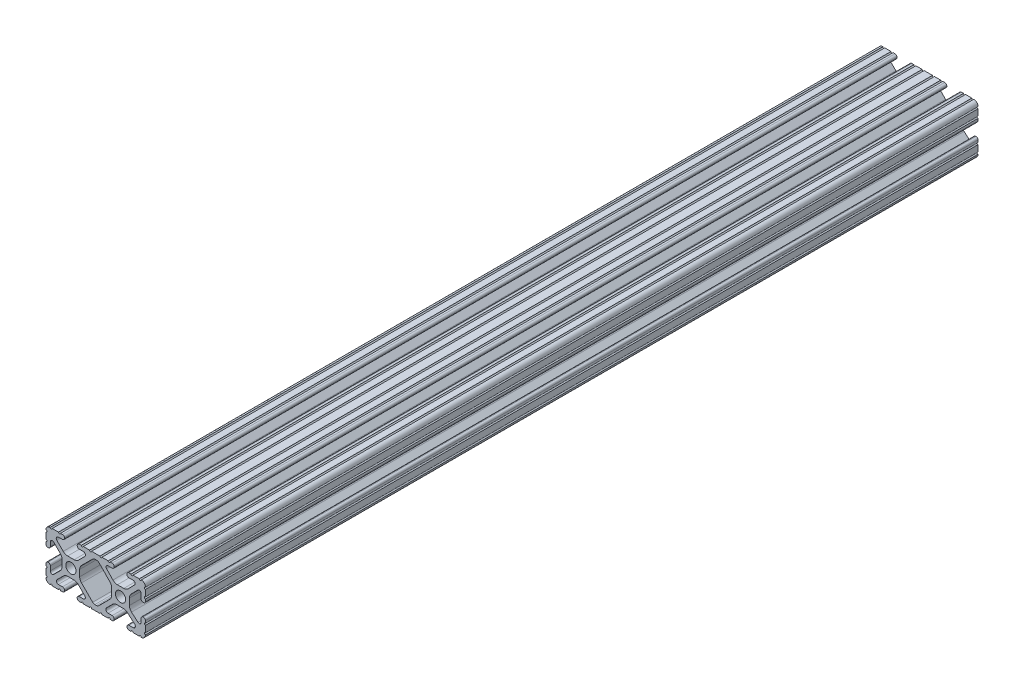
from build123d import *

# Parameters (mm, degrees)
SKETCH1_R           = 2.6035
BOSS_EXTRUDE1_DEPTH = 212.725


with BuildPart() as part:
    # Sketch1 → Boss-Extrude1 (new body, symmetric)
    with BuildSketch(Plane.XY):
        with BuildLine():
            Line((18.01710265, 12.7), (16.98745015, 12.7))
            ThreePointArc((16.98745015, 12.7), (16.245730386, 12.392769614), (15.9385, 11.65104985))
            Line((15.9385, 11.65104985), (15.9385, 11.53922))
            ThreePointArc((15.9385, 11.53922), (16.245750844, 10.797450844), (16.98752, 10.4902))
            Line((16.98752, 10.4902), (19.116384363, 10.4902))
            ThreePointArc((19.116384363, 10.4902), (20.052502933, 9.869096983), (19.844087081, 8.765172272))
            Line((19.844087081, 8.765172272), (16.618993479, 5.455112286))
            ThreePointArc((16.618993479, 5.455112286), (15.578994274, 4.745442459), (14.344932584, 4.4958))
            Line((14.344932584, 4.4958), (11.083317835, 4.4958))
            ThreePointArc((11.083317835, 4.4958), (9.854330953, 4.743306833), (8.816955189, 5.447238587))
            Line((8.816955189, 5.447238587), (5.564154119, 8.762652677))
            ThreePointArc((5.564154119, 8.762652677), (5.352591412, 9.867473037), (6.289393385, 10.4902))
            Line((6.289393385, 10.4902), (8.41248, 10.4902))
            ThreePointArc((8.41248, 10.4902), (9.154249156, 10.797450844), (9.4615, 11.53922))
            Line((9.4615, 11.53922), (9.4615, 11.65104985))
            ThreePointArc((9.4615, 11.65104985), (9.154269614, 12.392769614), (8.41254985, 12.7))
            Line((8.41254985, 12.7), (7.38288465, 12.7))
            ThreePointArc((7.38288465, 12.7), (6.87488465, 12.192), (6.36688465, 12.7))
            Line((6.36688465, 12.7), (3.14958095, 12.7))
            ThreePointArc((3.14958095, 12.7), (2.64158095, 12.192), (2.13358095, 12.7))
            Line((2.13358095, 12.7), (-2.13358095, 12.7))
            ThreePointArc((-2.13358095, 12.7), (-2.64158095, 12.192), (-3.14958095, 12.7))
            Line((-3.14958095, 12.7), (-6.36689735, 12.7))
            ThreePointArc((-6.36689735, 12.7), (-6.87489735, 12.192), (-7.38289735, 12.7))
            Line((-7.38289735, 12.7), (-8.41254985, 12.7))
            ThreePointArc((-8.41254985, 12.7), (-9.154269614, 12.392769614), (-9.4615, 11.65104985))
            Line((-9.4615, 11.65104985), (-9.4615, 11.53922))
            ThreePointArc((-9.4615, 11.53922), (-9.154249156, 10.797450844), (-8.41248, 10.4902))
            Line((-8.41248, 10.4902), (-6.283641037, 10.4902))
            ThreePointArc((-6.283641037, 10.4902), (-5.297291557, 9.829633109), (-5.532576693, 8.666071843))
            Line((-5.532576693, 8.666071843), (-8.809985098, 5.416263103))
            ThreePointArc((-8.809985098, 5.416263103), (-9.836720513, 4.734920264), (-11.045536121, 4.4958))
            Line((-11.045536121, 4.4958), (-14.354463879, 4.4958))
            ThreePointArc((-14.354463879, 4.4958), (-15.563279487, 4.734920264), (-16.590014902, 5.416263103))
            Line((-16.590014902, 5.416263103), (-19.867423307, 8.666071843))
            ThreePointArc((-19.867423307, 8.666071843), (-20.102708443, 9.829633109), (-19.116358963, 10.4902))
            Line((-19.116358963, 10.4902), (-16.98752, 10.4902))
            ThreePointArc((-16.98752, 10.4902), (-16.245750844, 10.797450844), (-15.9385, 11.53922))
            Line((-15.9385, 11.53922), (-15.9385, 11.65104985))
            ThreePointArc((-15.9385, 11.65104985), (-16.245730386, 12.392769614), (-16.98745015, 12.7))
            Line((-16.98745015, 12.7), (-18.01711535, 12.7))
            ThreePointArc((-18.01711535, 12.7), (-18.52511535, 12.192), (-19.03311535, 12.7))
            Line((-19.03311535, 12.7), (-22.2504, 12.7))
            ThreePointArc((-22.2504, 12.7), (-22.758323491, 12.192000006), (-23.266399977, 12.699846982))
            ThreePointArc((-23.266399977, 12.699846982), (-24.782522516, 12.082522516), (-25.399846982, 10.566399977))
            ThreePointArc((-25.399846982, 10.566399977), (-24.892000006, 10.058323491), (-25.4, 9.5504))
            Line((-25.4, 9.5504), (-25.4, 6.3330836))
            ThreePointArc((-25.4, 6.3330836), (-24.892, 5.8250836), (-25.4, 5.3170836))
            Line((-25.4, 5.3170836), (-25.4, 4.237520184))
            ThreePointArc((-25.4, 4.237520184), (-25.107393763, 3.531106237), (-24.400979816, 3.2385))
            Line((-24.400979816, 3.2385), (-24.23922, 3.2385))
            ThreePointArc((-24.23922, 3.2385), (-23.497450844, 3.545750844), (-23.1902, 4.28752))
            Line((-23.1902, 4.28752), (-23.1902, 6.334741132))
            ThreePointArc((-23.1902, 6.334741132), (-22.556026952, 7.286023527), (-21.434002553, 7.066535717))
            Line((-21.434002553, 7.066535717), (-18.147950853, 3.808156468))
            ThreePointArc((-18.147950853, 3.808156468), (-17.452759693, 2.774838327), (-17.208501877, 1.553619571))
            Line((-17.208501877, 1.553619571), (-17.208501877, -1.695179196))
            ThreePointArc((-17.208501877, -1.695179196), (-17.450738657, -2.911536421), (-18.140486065, -3.942289578))
            Line((-18.140486065, -3.942289578), (-21.431579576, -7.227386226))
            ThreePointArc((-21.431579576, -7.227386226), (-22.55444896, -7.449940594), (-23.1902, -6.498002195))
            Line((-23.1902, -6.498002195), (-23.1902, -4.28752))
            ThreePointArc((-23.1902, -4.28752), (-23.497450844, -3.545750844), (-24.23922, -3.2385))
            Line((-24.23922, -3.2385), (-24.35098, -3.2385))
            ThreePointArc((-24.35098, -3.2385), (-25.092749156, -3.545750844), (-25.4, -4.28752))
            Line((-25.4, -4.28752), (-25.4, -5.3171344))
            ThreePointArc((-25.4, -5.3171344), (-24.892, -5.8251344), (-25.4, -6.3331344))
            Line((-25.4, -6.3331344), (-25.4, -9.5504))
            ThreePointArc((-25.4, -9.5504), (-24.892000006, -10.058323491), (-25.399846982, -10.566399977))
            ThreePointArc((-25.399846982, -10.566399977), (-24.782522516, -12.082522516), (-23.266399977, -12.699846982))
            ThreePointArc((-23.266399977, -12.699846982), (-22.758323491, -12.192000006), (-22.2504, -12.7))
            Line((-22.2504, -12.7), (-19.03308995, -12.7))
            ThreePointArc((-19.03308995, -12.7), (-18.52508995, -12.192), (-18.01708995, -12.7))
            Line((-18.01708995, -12.7), (-16.9874692, -12.7))
            ThreePointArc((-16.9874692, -12.7), (-16.245700044, -12.392749156), (-15.9384492, -11.65098))
            Line((-15.9384492, -11.65098), (-15.9384492, -11.53922))
            ThreePointArc((-15.9384492, -11.53922), (-16.245700044, -10.797450844), (-16.9874692, -10.4902))
            Line((-16.9874692, -10.4902), (-19.116358963, -10.4902))
            ThreePointArc((-19.116358963, -10.4902), (-20.055197748, -9.862578342), (-19.834124023, -8.755124678))
            Line((-19.834124023, -8.755124678), (-16.49660751, -5.423689618))
            ThreePointArc((-16.49660751, -5.423689618), (-15.467274017, -4.736928798), (-14.253591699, -4.4958))
            Line((-14.253591699, -4.4958), (-11.146408301, -4.4958))
            ThreePointArc((-11.146408301, -4.4958), (-9.932725983, -4.736928798), (-8.90339249, -5.423689618))
            Line((-8.90339249, -5.423689618), (-5.565875977, -8.755124678))
            ThreePointArc((-5.565875977, -8.755124678), (-5.344802252, -9.862578342), (-6.283641037, -10.4902))
            Line((-6.283641037, -10.4902), (-8.4125308, -10.4902))
            ThreePointArc((-8.4125308, -10.4902), (-9.154299956, -10.797450844), (-9.4615508, -11.53922))
            Line((-9.4615508, -11.53922), (-9.4615508, -11.65098))
            ThreePointArc((-9.4615508, -11.65098), (-9.154299956, -12.392749156), (-8.4125308, -12.7))
            Line((-8.4125308, -12.7), (-7.38287195, -12.7))
            ThreePointArc((-7.38287195, -12.7), (-6.87487195, -12.192), (-6.36687195, -12.7))
            Line((-6.36687195, -12.7), (-3.14960635, -12.7))
            ThreePointArc((-3.14960635, -12.7), (-2.64160635, -12.192), (-2.13360635, -12.7))
            Line((-2.13360635, -12.7), (2.13360635, -12.7))
            ThreePointArc((2.13360635, -12.7), (2.64159365, -12.1920127), (3.14958095, -12.7))
            Line((3.14958095, -12.7), (6.36691005, -12.7))
            ThreePointArc((6.36691005, -12.7), (6.87491005, -12.192), (7.38291005, -12.7))
            Line((7.38291005, -12.7), (8.4125308, -12.7))
            ThreePointArc((8.4125308, -12.7), (9.154299956, -12.392749156), (9.4615508, -11.65098))
            Line((9.4615508, -11.65098), (9.4615508, -11.53922))
            ThreePointArc((9.4615508, -11.53922), (9.154299956, -10.797450844), (8.4125308, -10.4902))
            Line((8.4125308, -10.4902), (6.289393385, -10.4902))
            ThreePointArc((6.289393385, -10.4902), (5.231590322, -9.783049717), (5.480677245, -8.535265862))
            Line((5.480677245, -8.535265862), (8.597933595, -5.423689618))
            ThreePointArc((8.597933595, -5.423689618), (9.627267088, -4.736928798), (10.840949406, -4.4958))
            Line((10.840949406, -4.4958), (14.102564155, -4.4958))
            ThreePointArc((14.102564155, -4.4958), (15.215927525, -4.697410182), (16.187895372, -5.276636531))
            Line((16.187895372, -5.276636531), (19.868247549, -8.482246082))
            ThreePointArc((19.868247549, -8.482246082), (20.188435806, -9.746879864), (19.116384363, -10.4902))
            Line((19.116384363, -10.4902), (16.9874692, -10.4902))
            ThreePointArc((16.9874692, -10.4902), (16.245700044, -10.797450844), (15.9384492, -11.53922))
            Line((15.9384492, -11.53922), (15.9384492, -11.65098))
            ThreePointArc((15.9384492, -11.65098), (16.245700044, -12.392749156), (16.9874692, -12.7))
            Line((16.9874692, -12.7), (18.01710265, -12.7))
            ThreePointArc((18.01710265, -12.7), (18.52510265, -12.192), (19.03310265, -12.7))
            Line((19.03310265, -12.7), (22.2504, -12.7))
            ThreePointArc((22.2504, -12.7), (22.758323491, -12.192000006), (23.266399977, -12.699846982))
            ThreePointArc((23.266399977, -12.699846982), (24.782522516, -12.082522516), (25.399846982, -10.566399977))
            ThreePointArc((25.399846982, -10.566399977), (24.892000006, -10.058323492), (25.4, -9.550400001))
            Line((25.4, -9.550400001), (25.4, -6.333083592))
            ThreePointArc((25.4, -6.333083592), (24.892000001, -5.825083593), (25.4, -5.317083593))
            Line((25.4, -5.317083593), (25.4, -4.237520184))
            ThreePointArc((25.4, -4.237520184), (25.107393763, -3.531106237), (24.400979816, -3.2385))
            Line((24.400979816, -3.2385), (24.189220184, -3.2385))
            ThreePointArc((24.189220184, -3.2385), (23.482806237, -3.531106237), (23.1902, -4.237520184))
            Line((23.1902, -4.237520184), (23.1902, -6.155876159))
            ThreePointArc((23.1902, -6.155876159), (22.62232736, -7.038258539), (21.583974541, -6.886926384))
            Line((21.583974541, -6.886926384), (18.29817066, -4.024970844))
            ThreePointArc((18.29817066, -4.024970844), (17.493730985, -2.946044689), (17.208501877, -1.630807374))
            Line((17.208501877, -1.630807374), (17.208501877, 1.630807374))
            ThreePointArc((17.208501877, 1.630807374), (17.442348332, 2.82673414), (18.109440981, 3.846495088))
            Line((18.109440981, 3.846495088), (21.526346532, 7.353420386))
            ThreePointArc((21.526346532, 7.353420386), (22.585896263, 7.574939077), (23.1902, 6.676867167))
            Line((23.1902, 6.676867167), (23.1902, 4.237520184))
            ThreePointArc((23.1902, 4.237520184), (23.482806237, 3.531106237), (24.189220184, 3.2385))
            Line((24.189220184, 3.2385), (24.400979816, 3.2385))
            ThreePointArc((24.400979816, 3.2385), (25.107393763, 3.531106237), (25.4, 4.237520184))
            Line((25.4, 4.237520184), (25.4, 5.3170836))
            ThreePointArc((25.4, 5.3170836), (24.891949193, 5.825134407), (25.4, 6.333185215))
            Line((25.4, 6.333185215), (25.4, 9.550400015))
            ThreePointArc((25.4, 9.550400015), (24.892000013, 10.058323498), (25.399846982, 10.566399977))
            ThreePointArc((25.399846982, 10.566399977), (24.782522516, 12.082522516), (23.266399977, 12.699846982))
            ThreePointArc((23.266399977, 12.699846982), (22.758323491, 12.192000006), (22.2504, 12.7))
            Line((22.2504, 12.7), (19.03310265, 12.7))
            ThreePointArc((19.03310265, 12.7), (18.52510265, 12.192), (18.01710265, 12.7))
        make_face()
        with Locations((-12.7, 0)):
            Circle(SKETCH1_R, mode=Mode.SUBTRACT)
        with Locations((12.7, 0)):
            Circle(SKETCH1_R, mode=Mode.SUBTRACT)
        with BuildLine():
            Line((-7.259513935, -3.869413038), (-1.545748891, -9.572766749))
            ThreePointArc((-1.545748891, -9.572766749), (-1.035199478, -9.913400116), (-0.433213048, -10.033))
            Line((-0.433213048, -10.033), (0.433213048, -10.033))
            ThreePointArc((0.433213048, -10.033), (1.035199478, -9.913400116), (1.545748891, -9.572766749))
            Line((1.545748891, -9.572766749), (7.259513935, -3.869413038))
            ThreePointArc((7.259513935, -3.869413038), (7.949261343, -2.838659881), (8.191498123, -1.622302656))
            Line((8.191498123, -1.622302656), (8.191498123, 1.622302656))
            ThreePointArc((8.191498123, 1.622302656), (7.955573352, 2.823327967), (7.282860769, 3.845864069))
            Line((7.282860769, 3.845864069), (1.675572808, 9.561086461))
            ThreePointArc((1.675572808, 9.561086461), (1.161034429, 9.910236611), (0.551456936, 10.033))
            Line((0.551456936, 10.033), (-0.395199982, 10.033))
            ThreePointArc((-0.395199982, 10.033), (-0.994772524, 9.914396349), (-1.50403329, 9.576450301))
            Line((-1.50403329, 9.576450301), (-7.252049147, 3.876839553))
            ThreePointArc((-7.252049147, 3.876839553), (-7.947240307, 2.843521412), (-8.191498123, 1.622302656))
            Line((-8.191498123, 1.622302656), (-8.191498123, -1.622302656))
            ThreePointArc((-8.191498123, -1.622302656), (-7.949261343, -2.838659881), (-7.259513935, -3.869413038))
        make_face(mode=Mode.SUBTRACT)
    extrude(amount=BOSS_EXTRUDE1_DEPTH, both=True)


solid = part.part
